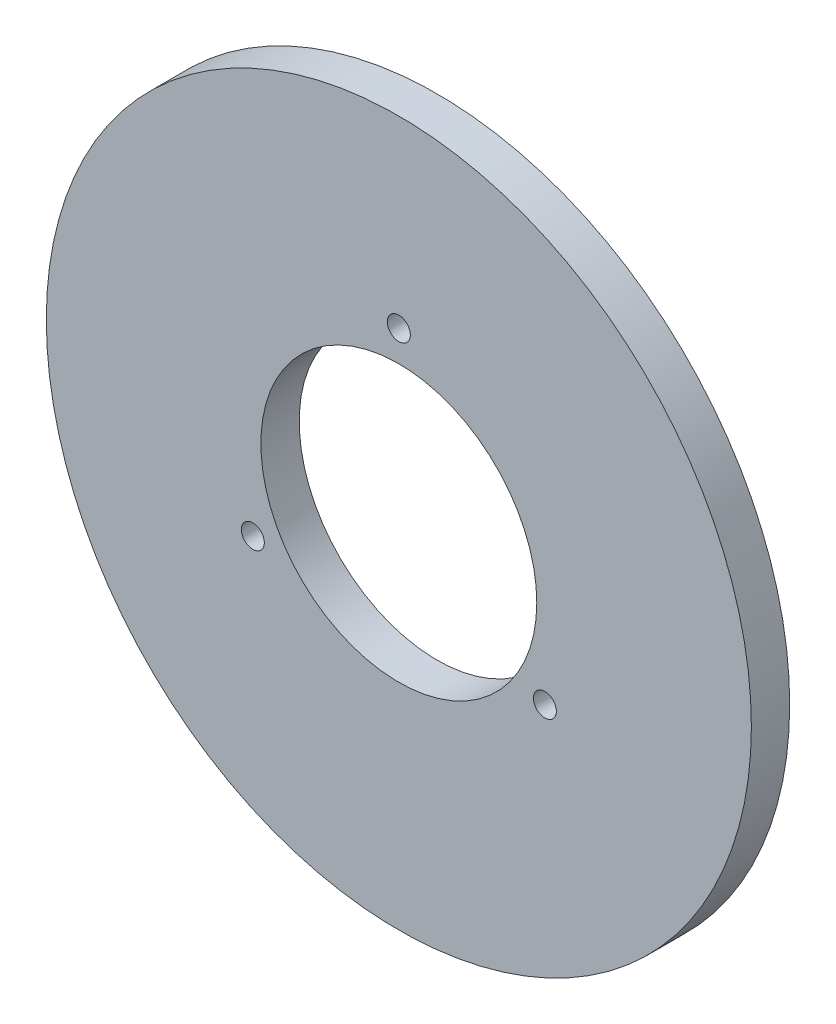
from build123d import *

# Parameters (mm, degrees)
SKETCH2_R               = 46
SKETCH2_R_2             = 18
BOSS_EXTRUDE2_DEPTH     = 5
SKETCH5_R               = 1.5
CUT_EXTRUDE1_DEPTH      = 1
CUT_EXTRUDE1_DEPTH_BACK = 6


with BuildPart() as part:
    # Sketch2 → Boss-Extrude2 (new body)
    with BuildSketch(Plane.XY):
        Circle(SKETCH2_R)
        Circle(SKETCH2_R_2, mode=Mode.SUBTRACT)
    extrude(amount=BOSS_EXTRUDE2_DEPTH)

    # Sketch5 → Cut-Extrude1 (cut, two sides)
    with BuildSketch(Plane(origin=(0, 0, 0), x_dir=(-1, 0, 0), z_dir=(0, 0, -1))) as cut_extrude1_sk:
        with Locations((0, 22)):
            Circle(SKETCH5_R)
        with Locations((19.052558883, -11)):
            Circle(SKETCH5_R)
        with Locations((-19.052558883, -11)):
            Circle(SKETCH5_R)
    extrude(amount=CUT_EXTRUDE1_DEPTH, mode=Mode.SUBTRACT)
    extrude(cut_extrude1_sk.sketch, amount=-CUT_EXTRUDE1_DEPTH_BACK, mode=Mode.SUBTRACT)


solid = part.part
